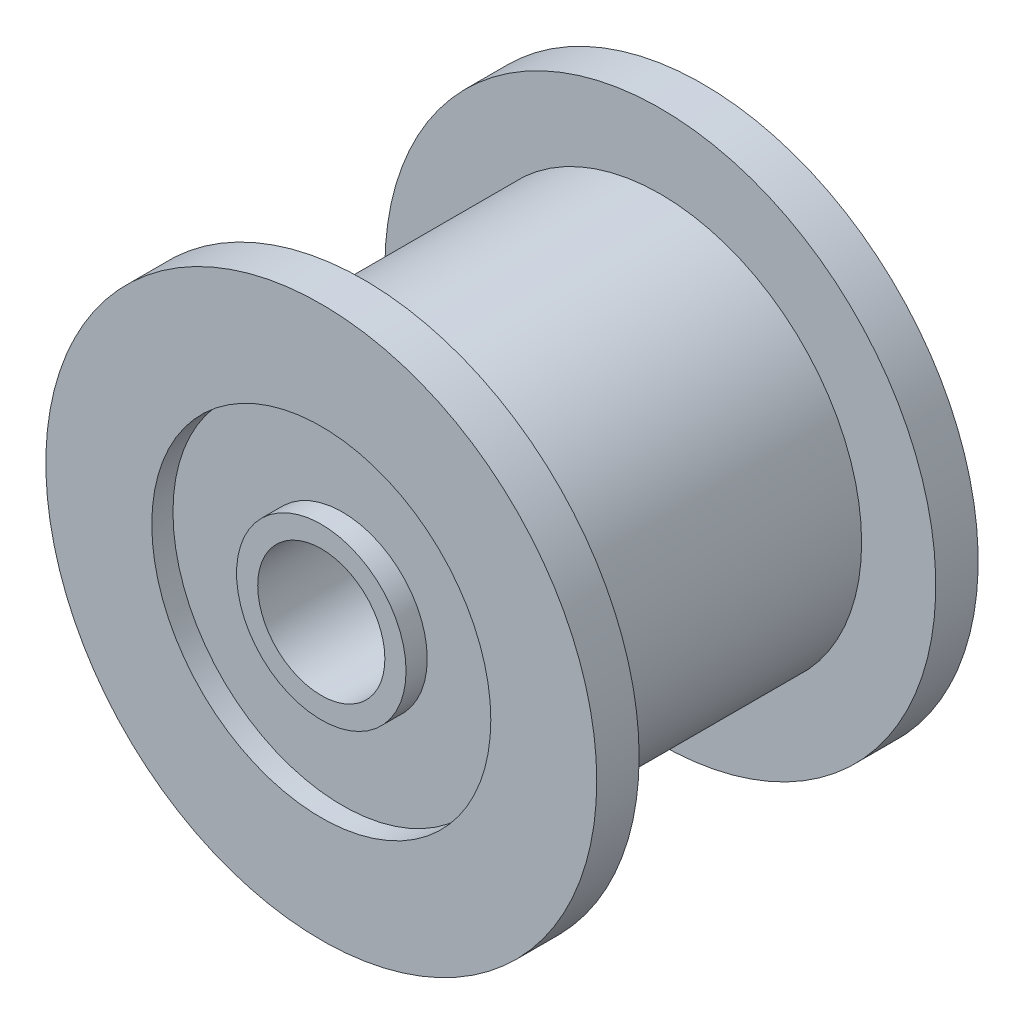
from build123d import *

# Parameters (mm, degrees)
SKETCH_1_R          = 4.75
EXTRUDE_1_DEPTH     = 7
SKETCH_2_R          = 6.5
EXTRUDE_2_DEPTH     = 1
SKETCH_3_R          = 6.5
EXTRUDE_3_DEPTH     = 1
SKETCH_4_R          = 1.5
CUT_EXTRUDE_1_DEPTH = 12
SKETCH_5_R          = 4
SKETCH_5_R_2        = 2
CUT_EXTRUDE_2_DEPTH = 0.5
SKETCH_6_R          = 4
SKETCH_6_R_2        = 2
CUT_EXTRUDE_3_DEPTH = 0.5


with BuildPart() as part:
    # 草图1 → 凸台-拉伸1 (new body)
    with BuildSketch(Plane.XY):
        Circle(SKETCH_1_R)
    extrude(amount=EXTRUDE_1_DEPTH)

    # 草图2 → 凸台-拉伸2 (add)
    with BuildSketch(Plane.XY.offset(7)):
        Circle(SKETCH_2_R)
    extrude(amount=EXTRUDE_2_DEPTH)

    # 草图3 → 凸台-拉伸3 (add)
    with BuildSketch(Plane(origin=(0, 0, 0), x_dir=(-1, 0, 0), z_dir=(0, 0, -1))):
        Circle(SKETCH_3_R)
    extrude(amount=EXTRUDE_3_DEPTH)

    # 草图4 → 切除-拉伸1 (cut)
    with BuildSketch(Plane(origin=(0, 0, -1), x_dir=(-1, 0, 0), z_dir=(0, 0, -1))):
        Circle(SKETCH_4_R)
    extrude(amount=-CUT_EXTRUDE_1_DEPTH, mode=Mode.SUBTRACT)

    # 草图5 → 切除-拉伸2 (cut)
    with BuildSketch(Plane(origin=(0, 0, -1), x_dir=(-1, 0, 0), z_dir=(0, 0, -1))):
        Circle(SKETCH_5_R)
        Circle(SKETCH_5_R_2, mode=Mode.SUBTRACT)
    extrude(amount=-CUT_EXTRUDE_2_DEPTH, mode=Mode.SUBTRACT)

    # 草图6 → 切除-拉伸3 (cut)
    with BuildSketch(Plane.XY.offset(8)):
        Circle(SKETCH_6_R)
        Circle(SKETCH_6_R_2, mode=Mode.SUBTRACT)
    extrude(amount=-CUT_EXTRUDE_3_DEPTH, mode=Mode.SUBTRACT)


solid = part.part
